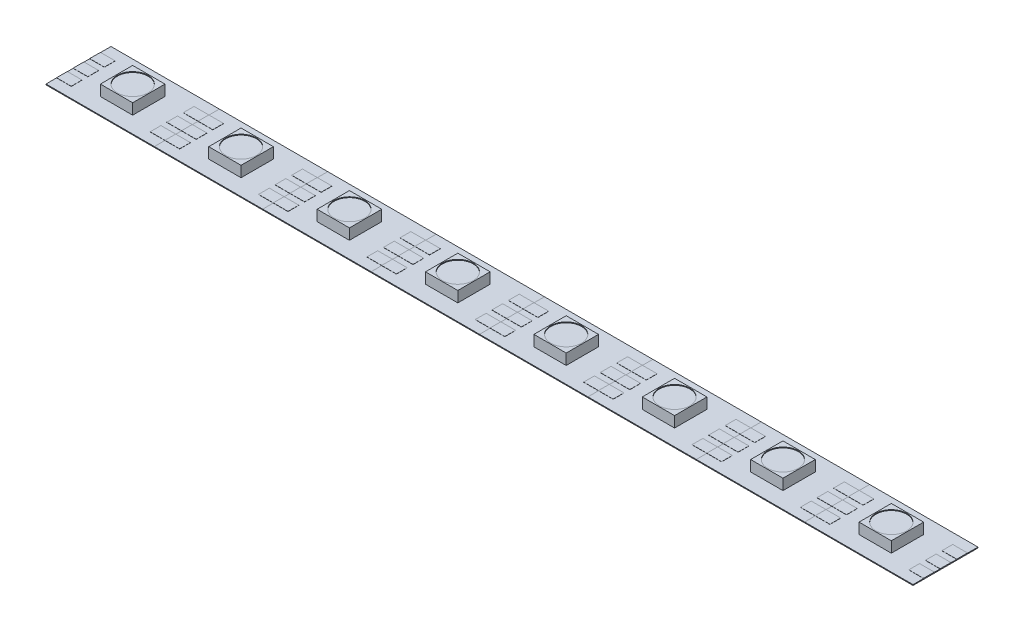
from build123d import *

# Parameters (mm, degrees)
SKETCH1_W           = 16.6116
SKETCH1_H           = 9.9568
BOSS_EXTRUDE1_DEPTH = 0.127
SKETCH3_W           = 4.953
SKETCH3_H           = 4.953
BOSS_EXTRUDE3_DEPTH = 1.651
SKETCH4_W           = 2.258810151
SKETCH4_H           = 1.651
BOSS_EXTRUDE4_DEPTH = 0.0254
SKETCH5_R           = 2.348345572
CUT_EXTRUDE1_DEPTH  = 0.127
LPATTERN1_COUNT     = 8
LPATTERN1_PITCH     = 16.6116


with BuildPart() as part:
    # Sketch1 → Boss-Extrude1 (new body)
    with BuildSketch(Plane(origin=(0, 0, 0), x_dir=(1, 0, 0), z_dir=(0, 1, 0))):
        Rectangle(SKETCH1_W, SKETCH1_H)
    extrude(amount=BOSS_EXTRUDE1_DEPTH)

    # Sketch3 → Boss-Extrude3 (add)
    with BuildSketch(Plane(origin=(0, 0.127, 0), x_dir=(1, 0, 0), z_dir=(0, 1, 0))):
        Rectangle(SKETCH3_W, SKETCH3_H)
    extrude(amount=BOSS_EXTRUDE3_DEPTH)

    # Sketch4 → Boss-Extrude4 (add)
    with BuildSketch(Plane(origin=(0, 0.127, 0), x_dir=(1, 0, 0), z_dir=(0, 1, 0))):
        with Locations((-7.176394925, 0)):
            Rectangle(SKETCH4_W, SKETCH4_H)
        with Locations((-7.176394925, 2.54)):
            Rectangle(SKETCH4_W, SKETCH4_H)
        with Locations((-7.176394925, -2.54)):
            Rectangle(SKETCH4_W, SKETCH4_H)
        with Locations((7.176394925, -2.54)):
            Rectangle(SKETCH4_W, SKETCH4_H)
        with Locations((7.176394925, 0)):
            Rectangle(SKETCH4_W, SKETCH4_H)
        with Locations((7.176394925, 2.54)):
            Rectangle(SKETCH4_W, SKETCH4_H)
    extrude(amount=BOSS_EXTRUDE4_DEPTH)

    # Sketch5 → Cut-Extrude1 (cut)
    with BuildSketch(Plane(origin=(0, 1.778, 0), x_dir=(1, 0, 0), z_dir=(0, 1, 0))):
        Circle(SKETCH5_R)
    extrude(amount=-CUT_EXTRUDE1_DEPTH, mode=Mode.SUBTRACT)


with BuildPart() as lpattern1_1:
    # LPattern1: pattern copy
    add(part.part.moved(Location(Vector(1, 0, 0) * (1 * LPATTERN1_PITCH))))


with BuildPart() as lpattern1_2:
    # LPattern1: pattern copy
    add(part.part.moved(Location(Vector(1, 0, 0) * (2 * LPATTERN1_PITCH))))


with BuildPart() as lpattern1_3:
    # LPattern1: pattern copy
    add(part.part.moved(Location(Vector(1, 0, 0) * (3 * LPATTERN1_PITCH))))


with BuildPart() as lpattern1_4:
    # LPattern1: pattern copy
    add(part.part.moved(Location(Vector(1, 0, 0) * (4 * LPATTERN1_PITCH))))


with BuildPart() as lpattern1_5:
    # LPattern1: pattern copy
    add(part.part.moved(Location(Vector(1, 0, 0) * (5 * LPATTERN1_PITCH))))


with BuildPart() as lpattern1_6:
    # LPattern1: pattern copy
    add(part.part.moved(Location(Vector(1, 0, 0) * (6 * LPATTERN1_PITCH))))


with BuildPart() as lpattern1_7:
    # LPattern1: pattern copy
    add(part.part.moved(Location(Vector(1, 0, 0) * (7 * LPATTERN1_PITCH))))


solid = Compound([part.part, lpattern1_1.part, lpattern1_2.part, lpattern1_3.part, lpattern1_4.part, lpattern1_5.part, lpattern1_6.part, lpattern1_7.part])
